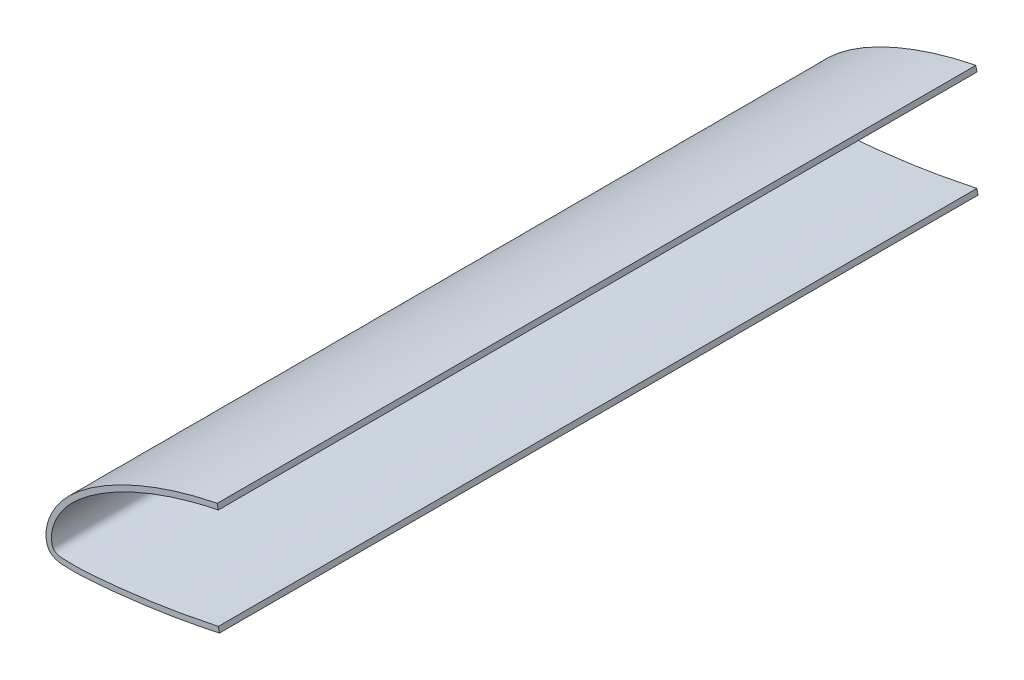
from build123d import *

# Parameters (mm, degrees)
BOSS_EXTRUDE1_DEPTH = 279.4


with BuildPart() as part:
    # Sketch1 → Boss-Extrude1 (new body)
    with BuildSketch(Plane.XY):
        with BuildLine():
            Line((0, 37.106504265), (-0.385480257, 39.067964439))
            add(Edge.make_bspline(
                [(-0.385480257, 39.067964439), (-3.327549192, 38.489767897), (-9.177511034, 37.147934885), (-17.814857495, 34.63490967), (-26.292287871, 31.600691236), (-34.571728192, 27.987174412), (-41.223423304, 24.422258778), (-46.342112304, 21.167591707), (-50.042038559, 18.491940207), (-53.576249459, 15.570515569), (-56.894204049, 12.276880758), (-59.301922845, 9.131296982), (-60.92798872, 6.411910095), (-61.986828393, 4.244914606), (-62.826076073, 1.947827014), (-63.304128596, -0.091065402), (-63.479085613, -1.819525935), (-63.468323744, -3.157555957), (-63.328723841, -4.26418283), (-63.114712397, -5.224789739), (-62.837127968, -6.034218273), (-62.359241154, -6.903915359), (-61.583108223, -7.694486143), (-60.788554124, -8.184798874), (-59.749833649, -8.625858472), (-58.56463909, -8.904754241), (-57.236700057, -9.034174006), (-56.08742663, -9.065495781), (-54.602873157, -9.10661824), (-52.698620359, -9.130912589), (-50.402570751, -9.074558082), (-48.144568806, -8.950711874), (-45.913987275, -8.797390382), (-42.939140833, -8.567518031), (-39.226259347, -8.227096129), (-34.786964302, -7.746798593), (-30.359223468, -7.214391974), (-24.468209218, -6.444139532), (-17.096681779, -5.357785311), (-8.30410286, -3.740684039), (-2.503261137, -2.553886462), (0.401550199, -1.95823351)],
                knots=[0.39025894, 0.39025894, 0.39025894, 0.39025894, 0.404156606, 0.418054273, 0.43195194, 0.445849607, 0.459747273, 0.466696107, 0.47364494, 0.480593773, 0.487542607, 0.49449144, 0.497965857, 0.501440274, 0.50491469, 0.508389107, 0.510126315, 0.511863524, 0.513600732, 0.514469336, 0.51533794, 0.516206544, 0.517075149, 0.517943753, 0.518812357, 0.520549565, 0.522286774, 0.524023982, 0.52576119, 0.529235607, 0.532710024, 0.53618444, 0.539658857, 0.543133274, 0.550082107, 0.55703094, 0.563979774, 0.570928607, 0.584826274, 0.598723941, 0.612621607, 0.612621607, 0.612621607, 0.612621607], degree=3))
            Line((0.401550199, -1.95823351), (0, 0))
            add(Edge.make_bspline(
                [(0, 37.106504265), (-0.500076224, 37.00822569), (-3.611615718, 36.379717103), (-9.188549224, 35.057340847), (-16.53917198, 32.91772684), (-23.427251137, 30.520369122), (-29.824095309, 27.919518004), (-35.689924299, 25.129183284), (-41.006560687, 22.204635542), (-45.745311706, 19.178697728), (-49.87675514, 16.091897726), (-53.400048205, 13.00847694), (-56.26304124, 9.89601769), (-58.452276546, 6.781318785), (-60.059523563, 3.758284242), (-61.076927022, 0.895017434), (-61.544309978, -1.741321043), (-61.416706932, -3.963881567), (-60.816240619, -5.995710908), (-58.67412511, -6.979086375), (-55.810710987, -7.081972506), (-51.8943465, -7.166071388), (-46.974516985, -6.886414892), (-41.104503109, -6.415895007), (-34.350470666, -5.698473801), (-26.781425901, -4.749253259), (-18.434582206, -3.55059719), (-9.424241657, -1.929527504), (-3.205972717, -0.657408311), (0, 0)],
                knots=[0.39025894, 0.39025894, 0.39025894, 0.39025894, 0.392652963, 0.405170359, 0.417171919, 0.428603517, 0.439418959, 0.449596586, 0.459102079, 0.467907878, 0.475988301, 0.483308969, 0.489874508, 0.49580325, 0.501149412, 0.505903073, 0.510046769, 0.513579311, 0.516446927, 0.519350053, 0.523823355, 0.529973794, 0.537715654, 0.546967844, 0.557637367, 0.569620481, 0.582804124, 0.597246961, 0.612621607, 0.612621607, 0.612621607, 0.612621607], degree=3))
        make_face()
    extrude(amount=BOSS_EXTRUDE1_DEPTH)


solid = part.part
